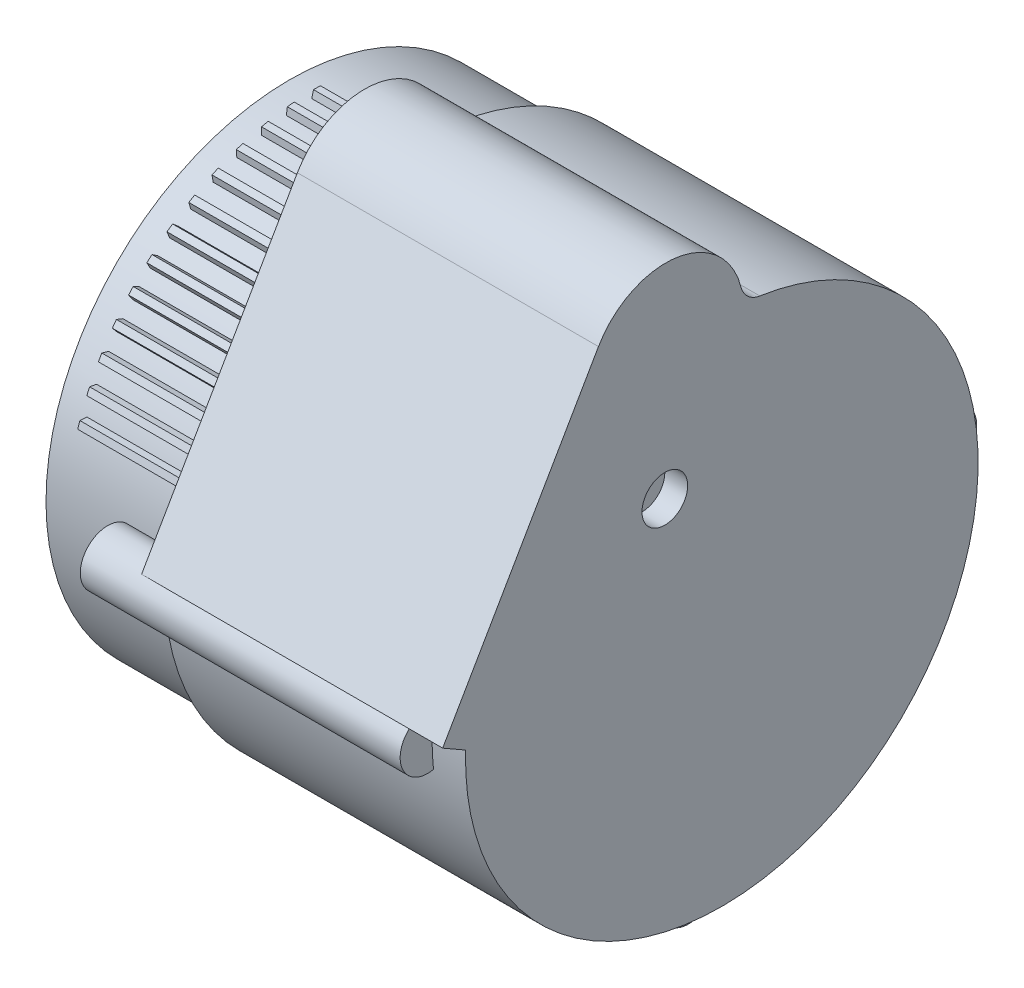
from build123d import *

# Parameters (mm, degrees)
SKETCH2_R           = 53.3
BOSS_EXTRUDE1_DEPTH = 94.62
BOSS_EXTRUDE2_DEPTH = 83
CIRPATTERN1_COUNT   = 13
CIRPATTERN1_ANGLE   = 72
BOSS_EXTRUDE3_START = -40
SKETCH5_R           = 6
BOSS_EXTRUDE3_DEPTH = 70
CIRPATTERN2_COUNT   = 3
CIRPATTERN2_ANGLE   = 180
SKETCH6_R           = 53.3
BOSS_EXTRUDE4_DEPTH = 65.9
FILLET2_R           = 5
SKETCH7_R           = 5
CUT_EXTRUDE1_DEPTH  = 5


with BuildPart() as part:
    # Sketch2 → Boss-Extrude1 (new body)
    with BuildSketch(Plane(origin=(0, 0, 0), x_dir=(0, 0, -1), z_dir=(1, 0, 0))):
        Circle(SKETCH2_R)
    extrude(amount=BOSS_EXTRUDE1_DEPTH)

    # Sketch4 → Boss-Extrude2 (add)
    with BuildSketch(Plane.ZY.offset(-6)):
        Polygon((-0.75, 54.8), (0.75, 54.8), (1.125, 53.288126023), (-1.125, 53.288126023), align=None)
    boss_extrude2 = extrude(amount=-BOSS_EXTRUDE2_DEPTH)

    # CirPattern1: Boss-Extrude2 ×13 about axis
    cirpattern1_axis = Axis((0, 0, 0), (1, 0, 0))
    for i in range(1, CIRPATTERN1_COUNT):
        add(boss_extrude2.rotate(cirpattern1_axis, i * CIRPATTERN1_ANGLE / (CIRPATTERN1_COUNT - 1)))

    # Sketch5 → Boss-Extrude3 (add)
    with BuildSketch(Plane.ZY.offset(-47.31).offset(BOSS_EXTRUDE3_START)):
        with Locations((-57.1, 0)):
            Circle(SKETCH5_R)
    boss_extrude3 = extrude(amount=BOSS_EXTRUDE3_DEPTH)

    # CirPattern2: Boss-Extrude3 ×3 about axis
    cirpattern2_axis = Axis((0, 0, 0), (-1, 0, 0))
    for i in range(1, CIRPATTERN2_COUNT):
        add(boss_extrude3.rotate(cirpattern2_axis, i * CIRPATTERN2_ANGLE / (CIRPATTERN2_COUNT - 1)))

    # Sketch6 → Boss-Extrude4 (add)
    with BuildSketch(Plane(origin=(94.62, 0, 0), x_dir=(0, 0, -1), z_dir=(1, 0, 0))):
        with BuildLine():
            Line((-61.1, 4.472135955), (-27, 63.535068493))
            ThreePointArc((-27, 63.535068493), (-8.298272765, 71.562778811), (4.70027417, 55.902749688))
            ThreePointArc((4.70027417, 55.902749688), (37.380543987, -41.831865022), (-56.077394681, 1.592421361))
            Line((-56.077394681, 1.592421361), (-61.1, 4.472135955))
        make_face()
        Circle(SKETCH6_R, mode=Mode.SUBTRACT)
    extrude(amount=-BOSS_EXTRUDE4_DEPTH)

    # Fillet2
    fillet2_edges = [part.edges().sort_by_distance(p)[0] for p in [
        (61.67, 55.902749688, -4.70027417),
    ]]
    fillet(fillet2_edges, radius=FILLET2_R)

    # Sketch7 → Cut-Extrude1 (cut)
    with BuildSketch(Plane(origin=(94.62, 0, 0), x_dir=(0, 0, -1), z_dir=(1, 0, 0))):
        with Locations((-12.475149036, 27.421809155)):
            Circle(SKETCH7_R)
    extrude(amount=-CUT_EXTRUDE1_DEPTH, mode=Mode.SUBTRACT)


solid = part.part
